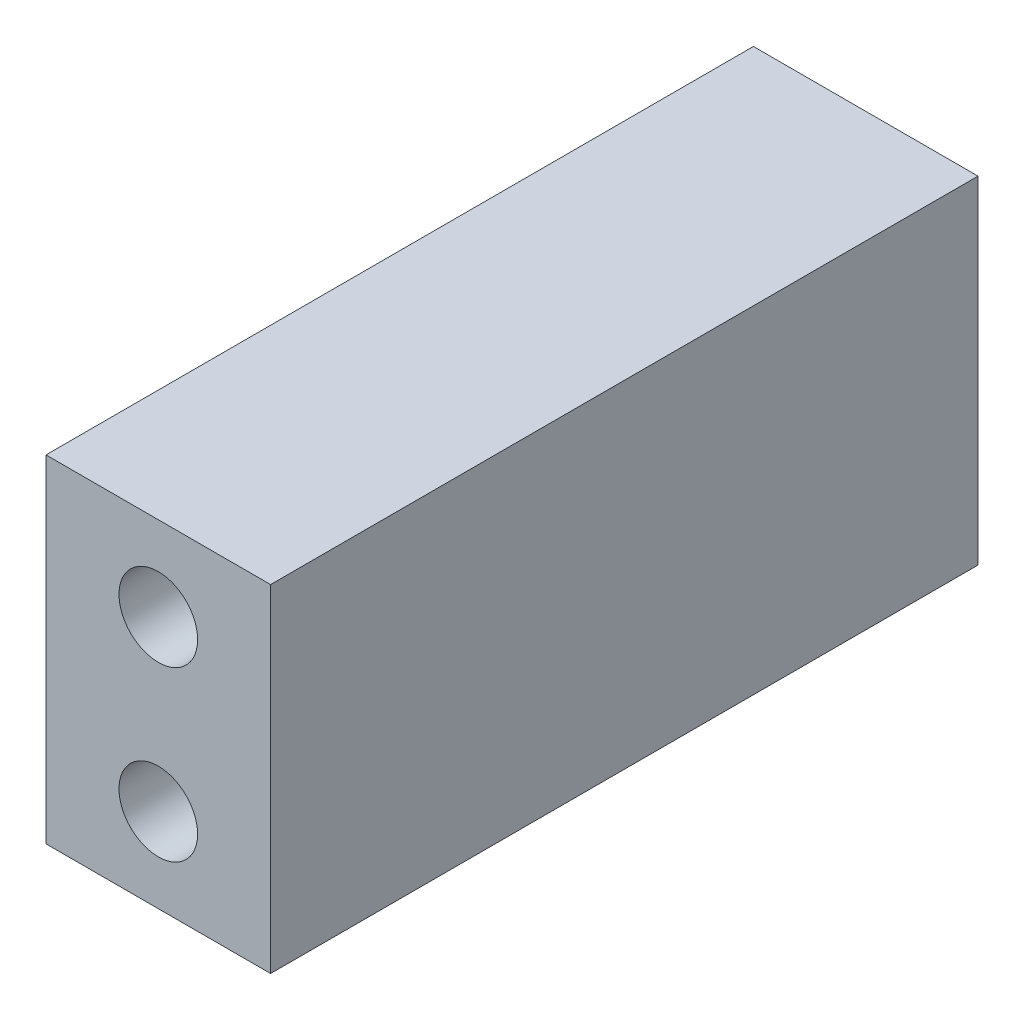
from build123d import *

# Parameters (mm, degrees)
SKETCH_1_W      = 20
SKETCH_1_H      = 30
SKETCH_1_R      = 3.5
EXTRUDE_1_DEPTH = 63


with BuildPart() as part:
    # 草图1 → 凸台-拉伸1 (new body)
    with BuildSketch(Plane.XY):
        Rectangle(SKETCH_1_W, SKETCH_1_H)
        with Locations((0, -7.5)):
            Circle(SKETCH_1_R, mode=Mode.SUBTRACT)
        with Locations((0, 7.5)):
            Circle(SKETCH_1_R, mode=Mode.SUBTRACT)
    extrude(amount=EXTRUDE_1_DEPTH)


solid = part.part
